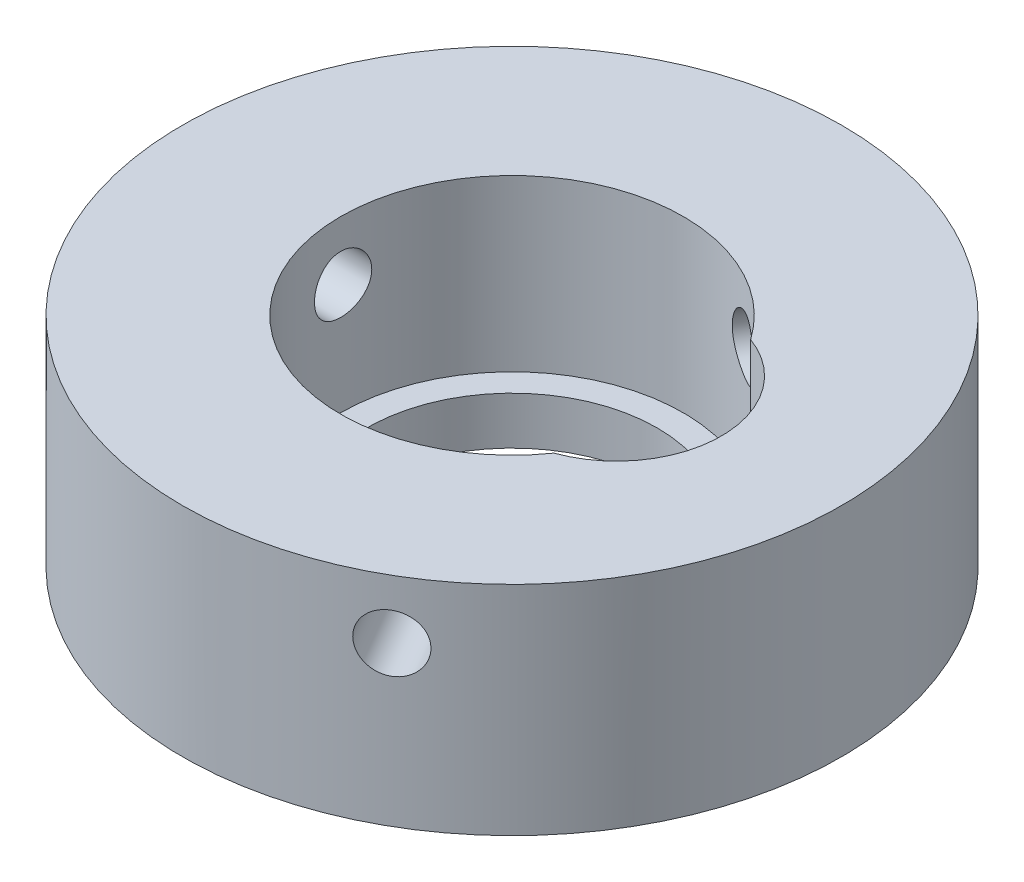
from build123d import *

# Parameters (mm, degrees)
SKETCH1_R           = 12.6
SKETCH1_R_2         = 6.55
BOSS_EXTRUDE1_DEPTH = 6.5
SKETCH2_R           = 1.095
CUT_EXTRUDE1_DEPTH  = 13.6
SKETCH4_R           = 12.6
SKETCH4_R_2         = 5.55
BOSS_EXTRUDE2_DEPTH = 1.82
CUT_EXTRUDE2_DEPTH  = 6.5
CIRPATTERN1_COUNT   = 3


with BuildPart() as part:
    # Sketch1 → Boss-Extrude1 (new body)
    with BuildSketch(Plane(origin=(0, 0, 0), x_dir=(1, 0, 0), z_dir=(0, 1, 0))):
        with Locations(Location((0, 0, 0), (0, 0, 270))):  # turned: the seam where the file's is
            Circle(SKETCH1_R)
        with Locations(Location((0, 0, 0), (0, 0, 270))):  # turned: the seam where the file's is
            Circle(SKETCH1_R_2, mode=Mode.SUBTRACT)
    extrude(amount=BOSS_EXTRUDE1_DEPTH)

    # Sketch2 → Cut-Extrude1 (cut, through all)
    with BuildSketch(Plane(origin=(0, 0, 0), x_dir=(0, 0, -1), z_dir=(1, 0, 0))):
        with Locations((0, 4.25)):
            Circle(SKETCH2_R)
    cut_extrude1 = extrude(amount=-CUT_EXTRUDE1_DEPTH, mode=Mode.SUBTRACT)

    # Sketch4 → Boss-Extrude2 (add)
    with BuildSketch(Plane.XZ):
        with Locations(Location((0, 0, 0), (0, 0, 270))):  # turned: the seam where the file's is
            Circle(SKETCH4_R)
        with Locations(Location((0, 0, 0), (0, 0, 270))):  # turned: the seam where the file's is
            Circle(SKETCH4_R_2, mode=Mode.SUBTRACT)
    extrude(amount=BOSS_EXTRUDE2_DEPTH)

    # Sketch3 → Cut-Extrude2 (cut)
    with BuildSketch(Plane(origin=(0, 6.5, 0), x_dir=(1, 0, 0), z_dir=(0, 1, 0))):
        with BuildLine():
            ThreePointArc((5.3628125, 3.760683726), (8, 0), (5.3628125, -3.760683726))
            ThreePointArc((5.3628125, -3.760683726), (6.55, 0), (5.3628125, 3.760683726))
        make_face()
    extrude(amount=-CUT_EXTRUDE2_DEPTH, mode=Mode.SUBTRACT)

    # CirPattern1: Cut-Extrude1 ×3 about axis
    cirpattern1_axis = Axis((0, 6.875, 0), (0, -1, 0))
    for i in range(1, CIRPATTERN1_COUNT):
        add(cut_extrude1.rotate(cirpattern1_axis, i * 360 / CIRPATTERN1_COUNT), mode=Mode.SUBTRACT)


solid = part.part
